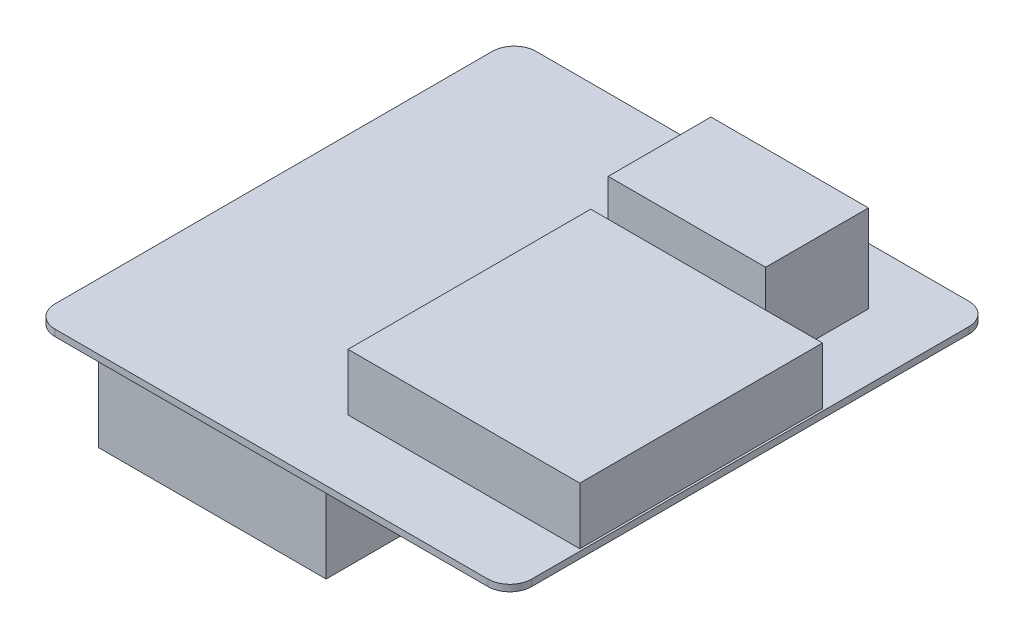
from build123d import *

# Parameters (mm, degrees)
ESQUISSE1_W        = 109
ESQUISSE1_H        = 110
BOSS_EXTRU_1_DEPTH = 1.5
CONG_1_R           = 5
ESQUISSE2_W        = 52
ESQUISSE2_H        = 85.5
BOSS_EXTRU_2_DEPTH = 29
ESQUISSE3_W        = 53
ESQUISSE3_H        = 55.5
ESQUISSE3_W_2      = 50
ESQUISSE3_H_2      = 49
BOSS_EXTRU_3_DEPTH = 13
ESQUISSE4_W        = 50
ESQUISSE4_H        = 49
BOSS_EXTRU_4_DEPTH = 13
ESQUISSE5_W        = 36
ESQUISSE5_H        = 23.5
BOSS_EXTRU_5_DEPTH = 20


with BuildPart() as part:
    # Esquisse1 → Boss.-Extru.1 (new body)
    with BuildSketch(Plane(origin=(0, 0, 0), x_dir=(1, 0, 0), z_dir=(0, 1, 0))):
        with Locations((54.5, 55)):
            Rectangle(ESQUISSE1_W, ESQUISSE1_H)
    extrude(amount=BOSS_EXTRU_1_DEPTH)

    # Congé1
    cong_1_edges = [part.edges().sort_by_distance(p)[0] for p in [
        (0, 0.75, -110),
        (109, 0.75, -110),
        (109, 0.75, 0),
        (0, 0.75, 0),
    ]]
    fillet(cong_1_edges, radius=CONG_1_R)

    # Esquisse2 → Boss.-Extru.2 (add)
    with BuildSketch(Plane.XZ):
        with Locations((29, -54.75)):
            Rectangle(ESQUISSE2_W, ESQUISSE2_H)
    extrude(amount=BOSS_EXTRU_2_DEPTH)

    # Esquisse3 → Boss.-Extru.3 (add)
    with BuildSketch(Plane(origin=(0, 1.5, 0), x_dir=(1, 0, 0), z_dir=(0, 1, 0))):
        with Locations((82, 44.25)):
            Rectangle(ESQUISSE3_W, ESQUISSE3_H)
        with Locations((82, 42.5)):
            Rectangle(ESQUISSE3_W_2, ESQUISSE3_H_2, mode=Mode.SUBTRACT)
    extrude(amount=BOSS_EXTRU_3_DEPTH)

    # Esquisse4 → Boss.-Extru.4 (add)
    with BuildSketch(Plane(origin=(0, 1.5, 0), x_dir=(1, 0, 0), z_dir=(0, 1, 0))):
        with Locations((82, 42.5)):
            Rectangle(ESQUISSE4_W, ESQUISSE4_H)
    extrude(amount=BOSS_EXTRU_4_DEPTH)

    # Esquisse5 → Boss.-Extru.5 (add)
    with BuildSketch(Plane(origin=(0, 1.5, 0), x_dir=(1, 0, 0), z_dir=(0, 1, 0))):
        with Locations((76, 85.25)):
            Rectangle(ESQUISSE5_W, ESQUISSE5_H)
    extrude(amount=BOSS_EXTRU_5_DEPTH)


solid = part.part
